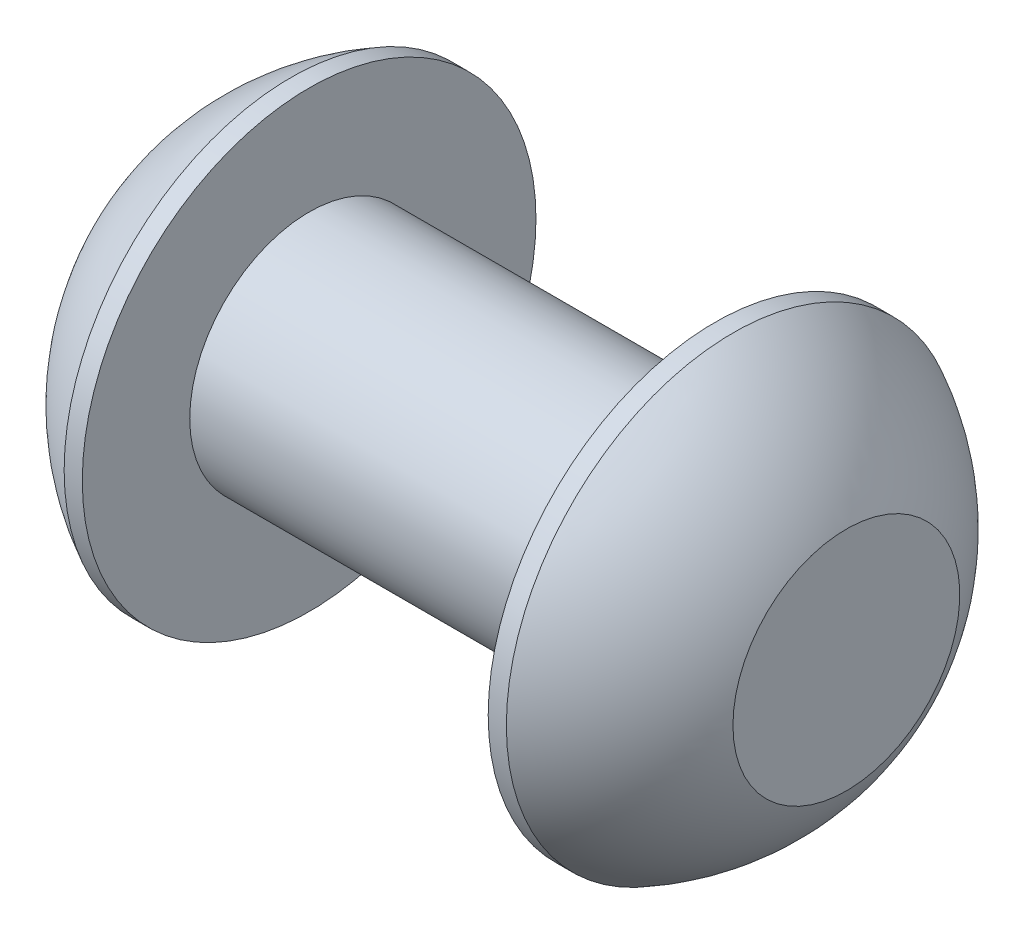
from build123d import *


with BuildPart() as part:
    # Sketch2 → Revolve1 (revolve)
    with BuildSketch(Plane.XY):
        with BuildLine():
            ThreePointArc((0, 2.375), (0.992680215, 3.754414901), (2.37, 4.75))
            Line((2.37, 4.75), (2.75, 4.75))
            Line((2.75, 4.75), (2.75, 2.5))
            Line((2.75, 2.5), (11.25, 2.5))
            Line((11.25, 2.5), (11.25, 4.75))
            Line((11.25, 4.75), (11.63, 4.75))
            ThreePointArc((11.63, 4.75), (13.007319785, 3.754414901), (14, 2.375))
            Line((14, 2.375), (14, 0))
            Line((14, 0), (0, 0))
            Line((0, 0), (0, 2.375))
        make_face()
    revolve(axis=Axis((-1.178114582, 0, 0), (1, 0, 0)))


solid = part.part
